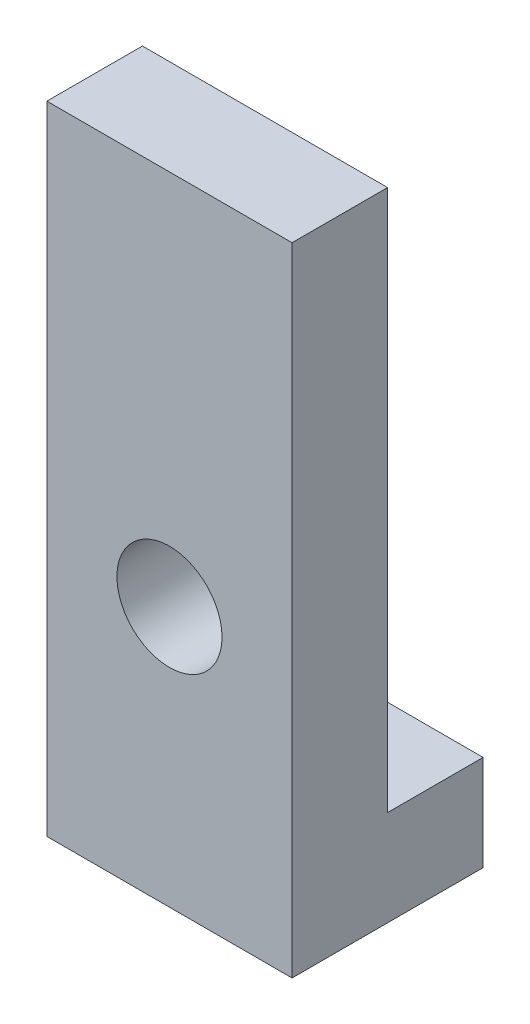
from build123d import *

# Parameters (mm, degrees)
SKETCH1_W           = 7.7
SKETCH1_H           = 17
SKETCH1_R           = 1.65
BOSS_EXTRUDE1_DEPTH = 3
SKETCH2_W           = 7.7
SKETCH2_H           = 6
BOSS_EXTRUDE2_DEPTH = 3


with BuildPart() as part:
    # Sketch1 → Boss-Extrude1 (new body)
    with BuildSketch(Plane.XY):
        with Locations((-5.65, -11.5)):
            Rectangle(SKETCH1_W, SKETCH1_H)
        with Locations((-5.65, -14.829504021)):
            Circle(SKETCH1_R, mode=Mode.SUBTRACT)
    extrude(amount=BOSS_EXTRUDE1_DEPTH)

    # Sketch2 → Boss-Extrude2 (add)
    with BuildSketch(Plane.XZ.offset(20)):
        with Locations((-5.65, 0)):
            Rectangle(SKETCH2_W, SKETCH2_H)
    extrude(amount=BOSS_EXTRUDE2_DEPTH)


solid = part.part
